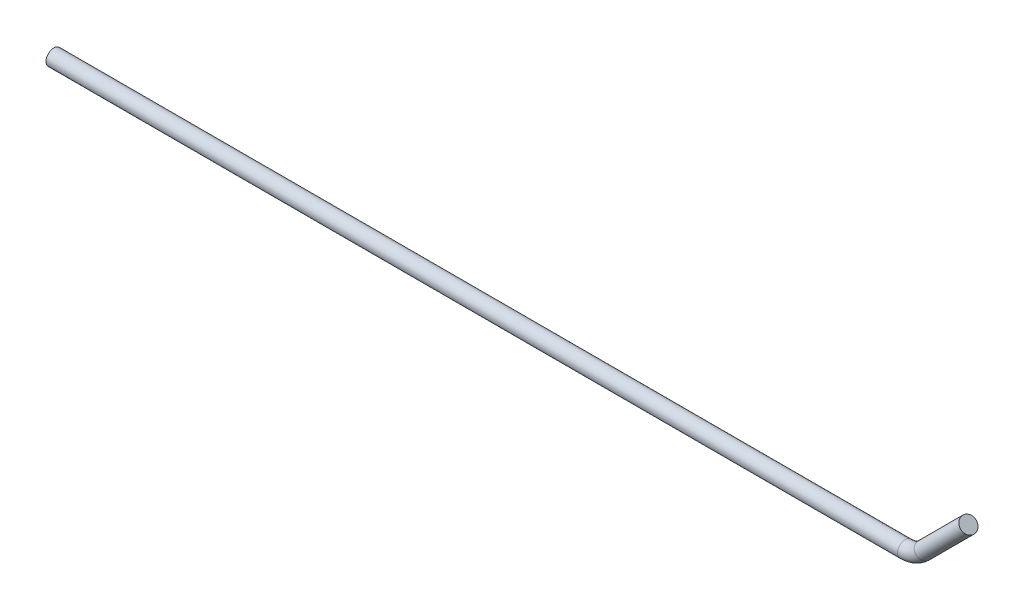
from build123d import *

# Parameters (mm, degrees)
SWEEP_1_PROFILE_R = 3


with BuildPart() as part:
    # По траектории1: sweep along a path in Эскиз17
    with BuildLine(Plane.XY) as sweep_1_path:
        Line((0, 0), (325.857864376, 0))
        ThreePointArc((325.857864376, 0), (329.6846987, 0.761204675), (332.928932188, 2.928932188))
        Line((332.928932188, 2.928932188), (350, 20))
    # По траектории1 profile (on start of the path) → По траектории1 (sweep)
    with BuildSketch(Plane(origin=(0, 0, 0), x_dir=(0, 0, 1), z_dir=(1, 0, 0))):
        Circle(SWEEP_1_PROFILE_R)
    sweep(path=sweep_1_path.line)


solid = part.part
